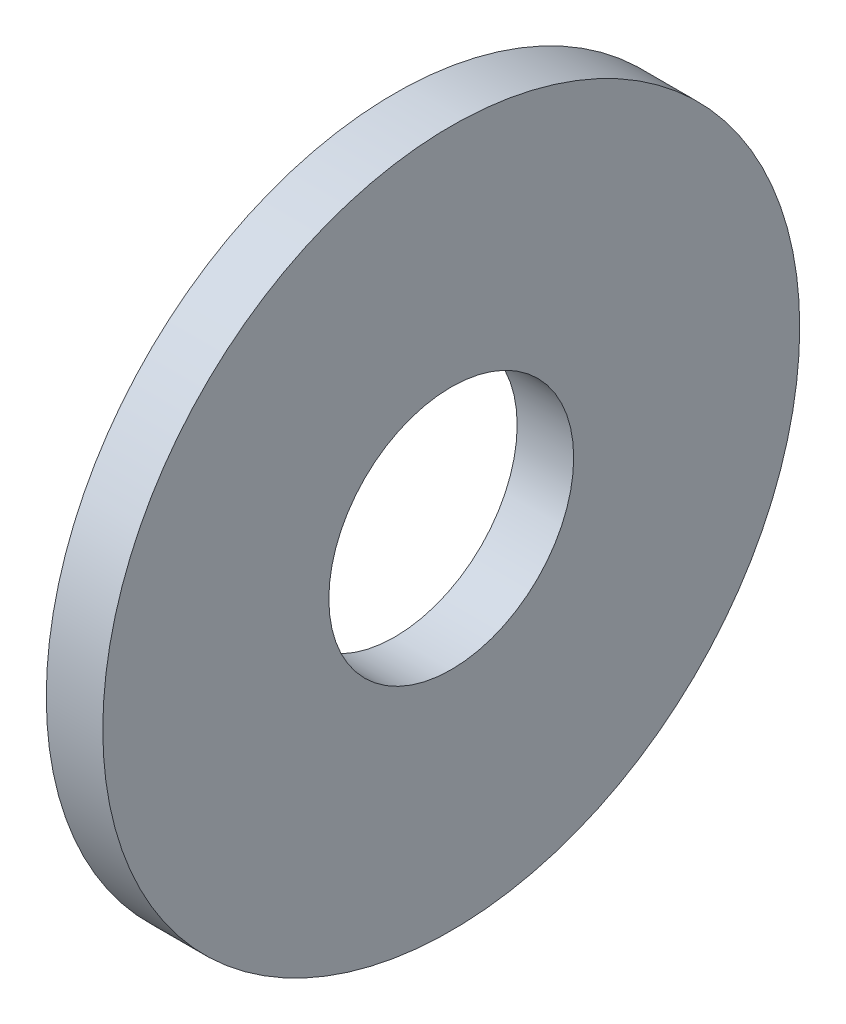
from build123d import *

# Parameters (mm, degrees)
SKETCH1_W = 3
SKETCH1_H = 12


with BuildPart() as part:
    # Sketch1 → Base-Revolve (revolve)
    with BuildSketch(Plane.XY):
        with Locations((-1.5, 12.5)):
            Rectangle(SKETCH1_W, SKETCH1_H)
    revolve(axis=Axis((-34.925, 0, 0), (1, 0, 0)))


solid = part.part
